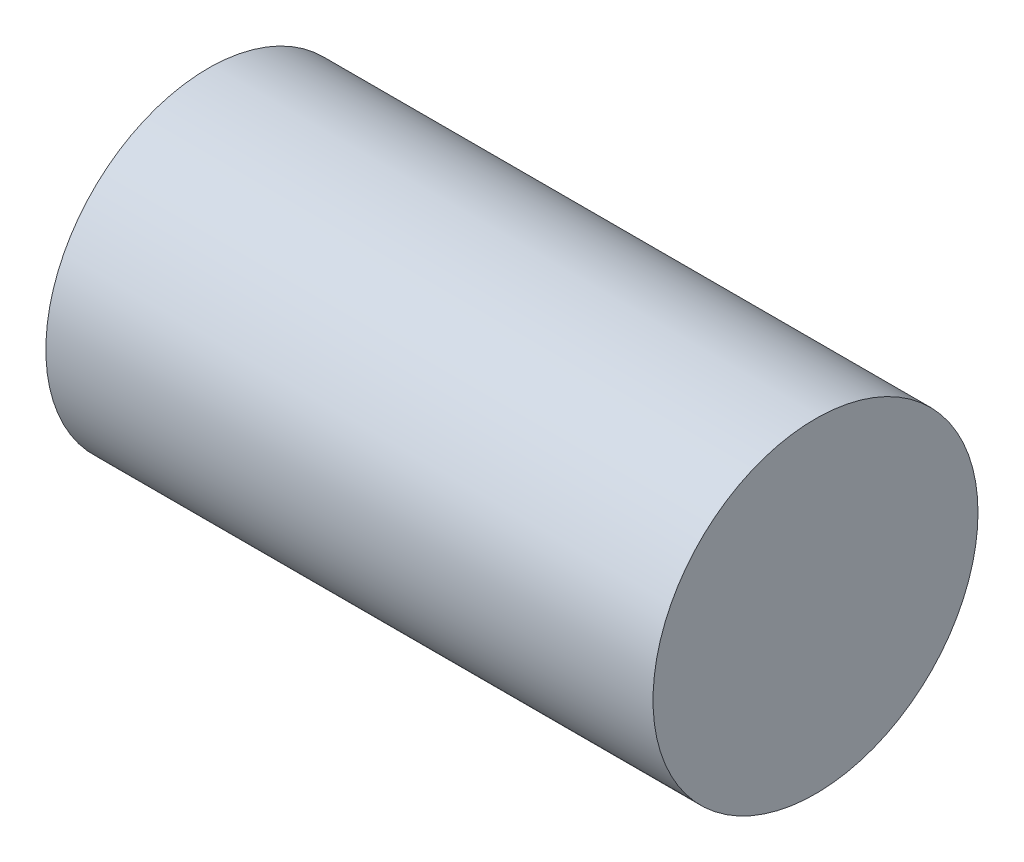
from build123d import *

# Parameters (mm, degrees)
SKETCH1_R           = 3.0861
BOSS_EXTRUDE1_DEPTH = 5.7658


with BuildPart() as part:
    # Sketch1 → Boss-Extrude1 (new body, symmetric)
    with BuildSketch(Plane(origin=(0, 0, 0), x_dir=(0, 0, -1), z_dir=(1, 0, 0))):
        Circle(SKETCH1_R)
    extrude(amount=BOSS_EXTRUDE1_DEPTH, both=True)


solid = part.part
